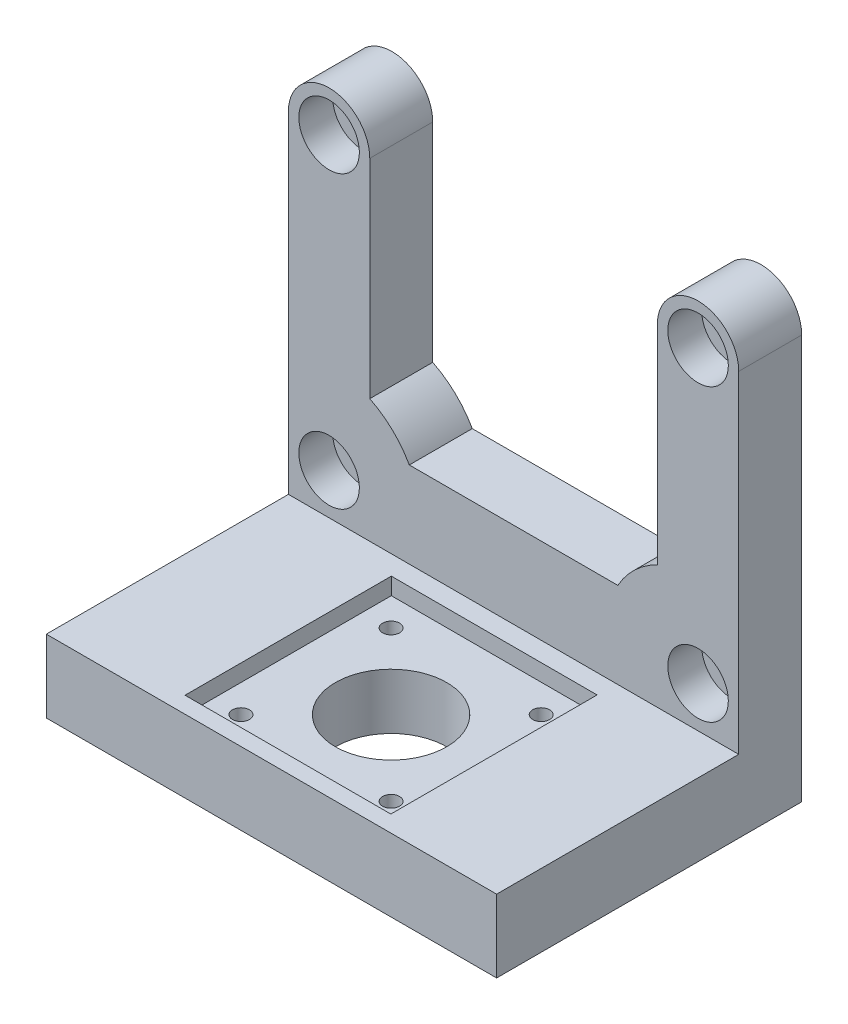
from build123d import *

# Parameters (mm, degrees)
BOSS_EXTRUDE1_DEPTH     = 93
SKETCH2_W               = 42.5
SKETCH2_H               = 42.6
CUT_EXTRUDE1_DEPTH      = 3.5
SKETCH3_R               = 11.5
CUT_EXTRUDE2_DEPTH      = 12.5
SKETCH4_R               = 1.75
CUT_EXTRUDE3_DEPTH      = 12.5
CUT_EXTRUDE4_START      = -11.5
SKETCH4_3_R             = 3
SKETCH4_3_R_2           = 1.75
CUT_EXTRUDE4_DEPTH      = 3
SKETCH5_R               = 3.25
CUT_EXTRUDE5_DEPTH      = 51
CUT_EXTRUDE5_DEPTH_BACK = 14
SKETCH5_3_R             = 6.25
SKETCH5_3_R_2           = 3.25
CUT_EXTRUDE6_DEPTH      = 51
CUT_EXTRUDE6_DEPTH_BACK = 7
CUT_EXTRUDE7_DEPTH      = 14


with BuildPart() as part:
    # Sketch1 → Boss-Extrude1 (new body)
    with BuildSketch(Plane(origin=(0, 0, 0), x_dir=(0, 0, -1), z_dir=(1, 0, 0))):
        Polygon((0, 0), (-50, 0), (-50, -15), (13, -15), (13, 86.965010888), (0, 86.965010888), align=None)
    extrude(amount=-BOSS_EXTRUDE1_DEPTH)

    # Sketch2 → Cut-Extrude1 (cut)
    with BuildSketch(Plane(origin=(0, 0, 0), x_dir=(1, 0, 0), z_dir=(0, 1, 0))):
        with Locations((-46.5, -25.3)):
            Rectangle(SKETCH2_W, SKETCH2_H)
    extrude(amount=-CUT_EXTRUDE1_DEPTH, mode=Mode.SUBTRACT)

    # Sketch3 → Cut-Extrude2 (cut, through all)
    with BuildSketch(Plane(origin=(0, -3.5, 0), x_dir=(1, 0, 0), z_dir=(0, 1, 0))):
        with Locations((-46.5, -25.3)):
            Circle(SKETCH3_R)
    extrude(amount=-CUT_EXTRUDE2_DEPTH, mode=Mode.SUBTRACT)

    # Sketch4 → Cut-Extrude3 (cut, through all)
    with BuildSketch(Plane(origin=(0, -3.5, 0), x_dir=(1, 0, 0), z_dir=(0, 1, 0))):
        with Locations((-62, -9.8)):
            Circle(SKETCH4_R)
        with Locations((-31, -9.8)):
            Circle(SKETCH4_R)
        with Locations((-31, -40.8)):
            Circle(SKETCH4_R)
        with Locations((-62, -40.8)):
            Circle(SKETCH4_R)
    extrude(amount=-CUT_EXTRUDE3_DEPTH, mode=Mode.SUBTRACT)

    # Sketch4_3 → Cut-Extrude4 (cut)
    with BuildSketch(Plane(origin=(0, -3.5, 0), x_dir=(1, 0, 0), z_dir=(0, 1, 0)).offset(CUT_EXTRUDE4_START)):
        with Locations((-62, -9.8)):
            Circle(SKETCH4_3_R)
        with Locations((-62, -9.8)):
            Circle(SKETCH4_3_R_2, mode=Mode.SUBTRACT)
        with Locations((-31, -9.8)):
            Circle(SKETCH4_3_R)
        with Locations((-31, -9.8)):
            Circle(SKETCH4_3_R_2, mode=Mode.SUBTRACT)
        with Locations((-31, -40.8)):
            Circle(SKETCH4_3_R)
        with Locations((-31, -40.8)):
            Circle(SKETCH4_3_R_2, mode=Mode.SUBTRACT)
        with Locations((-62, -40.8)):
            Circle(SKETCH4_3_R)
        with Locations((-62, -40.8)):
            Circle(SKETCH4_3_R_2, mode=Mode.SUBTRACT)
    extrude(amount=CUT_EXTRUDE4_DEPTH, mode=Mode.SUBTRACT)

    # Sketch5 → Cut-Extrude5 (cut, two sides)
    with BuildSketch(Plane.XY) as cut_extrude5_sk:
        with Locations((-84.6, 68.5)):
            Circle(SKETCH5_R)
        with Locations((-8.4, 68.5)):
            Circle(SKETCH5_R)
        with Locations((-8.4, 8.5)):
            Circle(SKETCH5_R)
        with Locations((-84.6, 8.5)):
            Circle(SKETCH5_R)
    extrude(amount=CUT_EXTRUDE5_DEPTH, mode=Mode.SUBTRACT)
    extrude(cut_extrude5_sk.sketch, amount=-CUT_EXTRUDE5_DEPTH_BACK, mode=Mode.SUBTRACT)

    # Sketch5_3 → Cut-Extrude6 (cut, two sides)
    with BuildSketch(Plane.XY) as cut_extrude6_sk:
        with Locations((-84.6, 68.5)):
            Circle(SKETCH5_3_R)
        with Locations((-84.6, 68.5)):
            Circle(SKETCH5_3_R_2, mode=Mode.SUBTRACT)
        with Locations((-84.6, 8.5)):
            Circle(SKETCH5_3_R)
        with Locations((-84.6, 8.5)):
            Circle(SKETCH5_3_R_2, mode=Mode.SUBTRACT)
        with Locations((-8.4, 8.5)):
            Circle(SKETCH5_3_R)
        with Locations((-8.4, 8.5)):
            Circle(SKETCH5_3_R_2, mode=Mode.SUBTRACT)
        with Locations((-8.4, 68.5)):
            Circle(SKETCH5_3_R)
        with Locations((-8.4, 68.5)):
            Circle(SKETCH5_3_R_2, mode=Mode.SUBTRACT)
    extrude(amount=CUT_EXTRUDE6_DEPTH, mode=Mode.SUBTRACT)
    extrude(cut_extrude6_sk.sketch, amount=-CUT_EXTRUDE6_DEPTH_BACK, mode=Mode.SUBTRACT)

    # Sketch7 → Cut-Extrude7 (cut, through all)
    with BuildSketch(Plane.XY):
        with BuildLine():
            Line((-93, 86.965010888), (-93, 68.5))
            ThreePointArc((-93, 68.5), (-84.6, 76.9), (-76.2, 68.5))
            Line((-76.2, 68.5), (-76.2, 25.508589177))
            ThreePointArc((-76.2, 25.508589177), (-71.526556974, 22.245442635), (-68.033447852, 17.741290803))
            Line((-68.033447852, 17.741290803), (-24.966552148, 17.741290803))
            ThreePointArc((-24.966552148, 17.741290803), (-21.473443026, 22.245442635), (-16.8, 25.508589177))
            Line((-16.8, 25.508589177), (-16.8, 68.5))
            ThreePointArc((-16.8, 68.5), (-8.4, 76.9), (0, 68.5))
            Line((0, 68.5), (0, 86.965010888))
            Line((0, 86.965010888), (-93, 86.965010888))
        make_face()
    extrude(amount=-CUT_EXTRUDE7_DEPTH, mode=Mode.SUBTRACT)


solid = part.part
